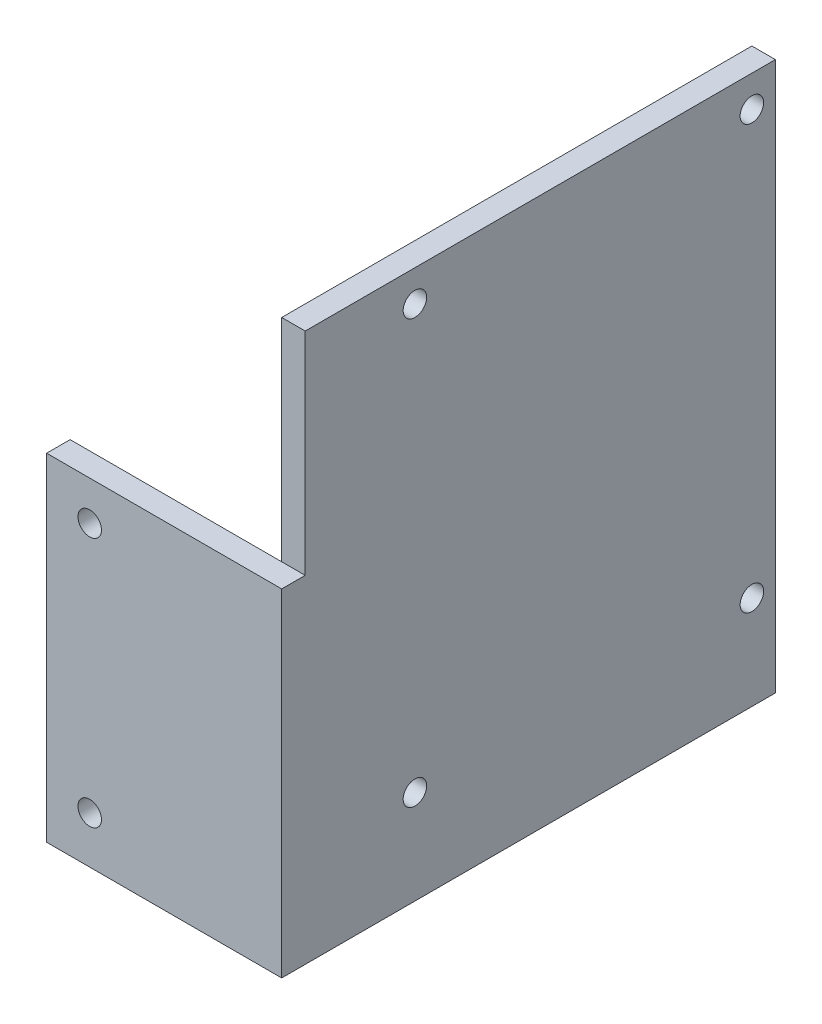
from build123d import *

# Parameters (mm, degrees)
CROQUIS1_W              = 30
CROQUIS1_H              = 43
CROQUIS1_R              = 1.5
SALIENTE_EXTRUIR1_DEPTH = 3
CROQUIS2_W              = 60
CROQUIS2_H              = 70
CROQUIS2_R              = 1.5
SALIENTE_EXTRUIR2_DEPTH = 3


with BuildPart() as part:
    # Croquis1 → Saliente-Extruir1 (new body)
    with BuildSketch(Plane.XY):
        with Locations((-25.378630764, -5.032160817)):
            Rectangle(CROQUIS1_W, CROQUIS1_H)
        with Locations((-34.878630764, 11.467839183)):
            Circle(CROQUIS1_R, mode=Mode.SUBTRACT)
        with Locations((-34.878630764, -20.532160817)):
            Circle(CROQUIS1_R, mode=Mode.SUBTRACT)
    extrude(amount=SALIENTE_EXTRUIR1_DEPTH)

    # Croquis2 → Saliente-Extruir2 (add)
    with BuildSketch(Plane(origin=(-10.378630764, 0, 0), x_dir=(0, 0, -1), z_dir=(1, 0, 0))):
        with Locations((30, 8.467839183)):
            Rectangle(CROQUIS2_W, CROQUIS2_H)
        with Locations((57, 39.467839183)):
            Circle(CROQUIS2_R, mode=Mode.SUBTRACT)
        with Locations((14, 39.467839183)):
            Circle(CROQUIS2_R, mode=Mode.SUBTRACT)
        with Locations((14, -14.532160817)):
            Circle(CROQUIS2_R, mode=Mode.SUBTRACT)
        with Locations((57, -14.532160817)):
            Circle(CROQUIS2_R, mode=Mode.SUBTRACT)
    extrude(amount=-SALIENTE_EXTRUIR2_DEPTH)


solid = part.part
